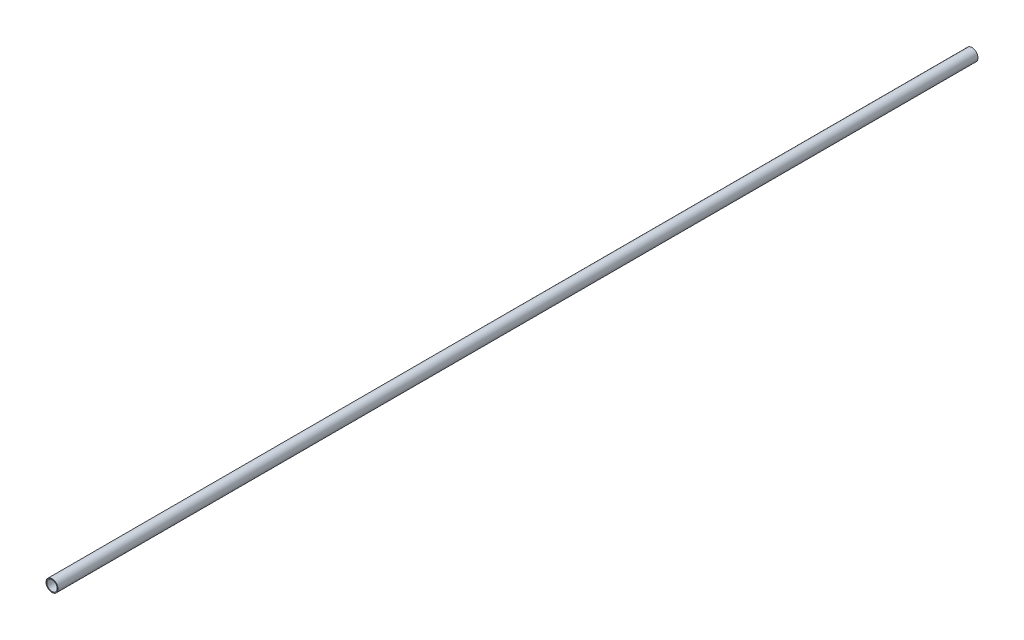
from build123d import *

# Parameters (mm, degrees)
SKETCH1_R           = 6.35
SKETCH1_R_2         = 5.5
EXTRUDE_THIN1_DEPTH = 976


with BuildPart() as part:
    # Sketch1 → Extrude-Thin1 (new body)
    with BuildSketch(Plane.XY):
        Circle(SKETCH1_R)
        Circle(SKETCH1_R_2, mode=Mode.SUBTRACT)
    extrude(amount=EXTRUDE_THIN1_DEPTH)


solid = part.part
